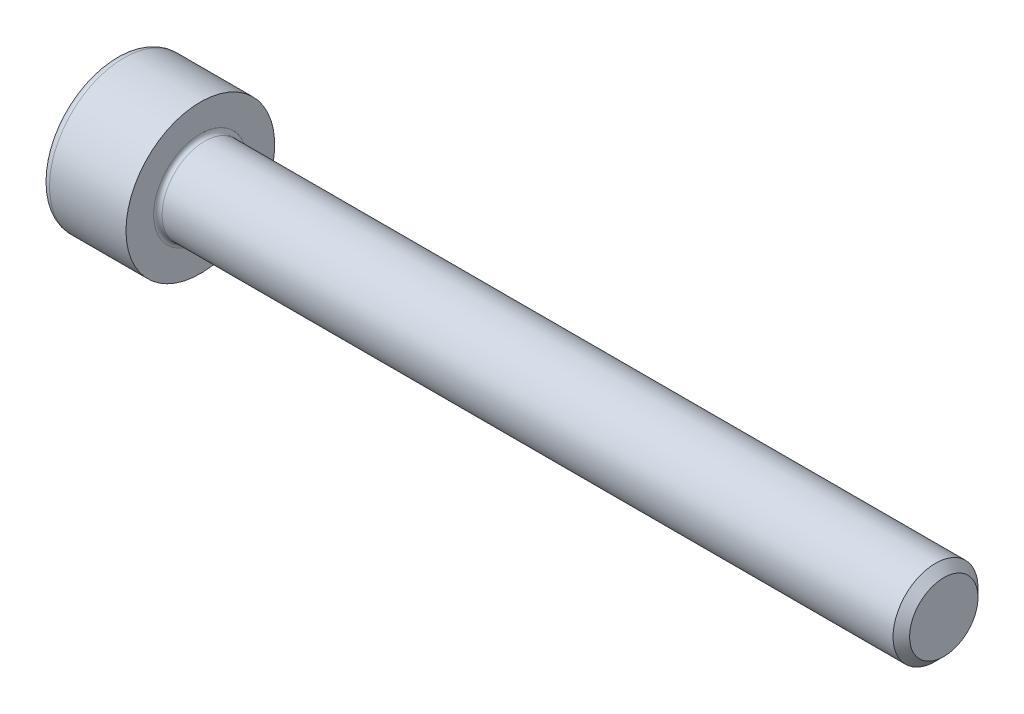
from build123d import *

# Parameters (mm, degrees)
FILLET1_R   = 0.2
FILLET2_R   = 0.4
HEX_2_DEPTH = 2


with BuildPart() as part:
    # BodySke → Base-Revolve (revolve)
    with BuildSketch(Plane.XY):
        Polygon((0, 0), (0, 3.5), (4, 3.5), (4, 2), (38.61, 2), (39, 1.61), (39, 0), align=None)
    revolve(axis=Axis((-31.75, 0, 0), (1, 0, 0)))

    # Fillet1
    fillet1_edges = [part.edges().sort_by_distance(p)[0] for p in [
        (4, -2, 0),
    ]]
    fillet(fillet1_edges, radius=FILLET1_R)

    # Fillet2
    fillet2_edges = [part.edges().sort_by_distance(p)[0] for p in [
        (0, -3.5, 0),
    ]]
    fillet(fillet2_edges, radius=FILLET2_R)

    # Sketch2 → Hex-PreBroach (revolve, cut)
    with BuildSketch(Plane.XY):
        Polygon((0, 1.51), (2, 1.51), (2.871798906, 0), (0, 0), align=None)
    revolve(axis=Axis((0, 0, 0), (1, 0, 0)), mode=Mode.SUBTRACT)

    # Sketch3 → Hex 2 (cut)
    with BuildSketch(Plane(origin=(0, 0, 0), x_dir=(0, 0.5, 0.866025404), z_dir=(-1, 0, 0))):
        Polygon((0.871798906, 1.51), (-0.871798906, 1.51), (-1.743597813, 0), (-0.871798906, -1.51), (0.871798906, -1.51), (1.743597813, 0), align=None)
    extrude(amount=-HEX_2_DEPTH, mode=Mode.SUBTRACT)


solid = part.part
